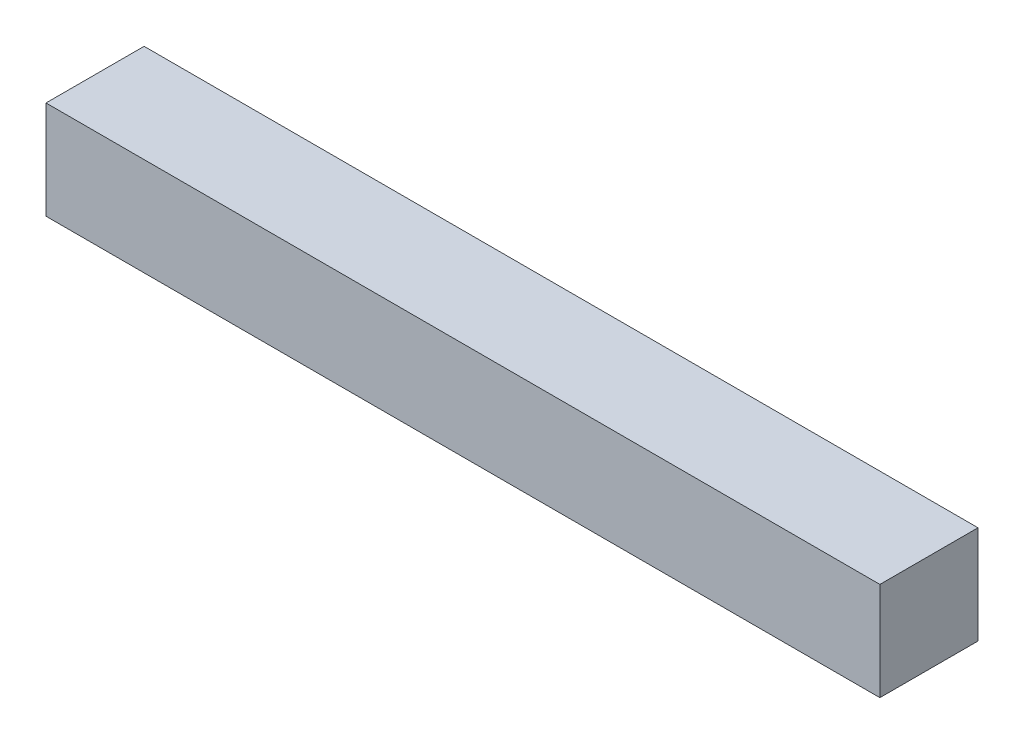
from build123d import *

# Parameters (mm, degrees)
SKETCH_1_W      = 100
SKETCH_1_H      = 100
EXTRUDE_1_DEPTH = 850


with BuildPart() as part:
    # Эскиз1 → Бобышка-Вытянуть1 (new body)
    with BuildSketch(Plane(origin=(0, 0, 0), x_dir=(0, 0, -1), z_dir=(1, 0, 0))):
        Rectangle(SKETCH_1_W, SKETCH_1_H)
    extrude(amount=EXTRUDE_1_DEPTH)


solid = part.part
